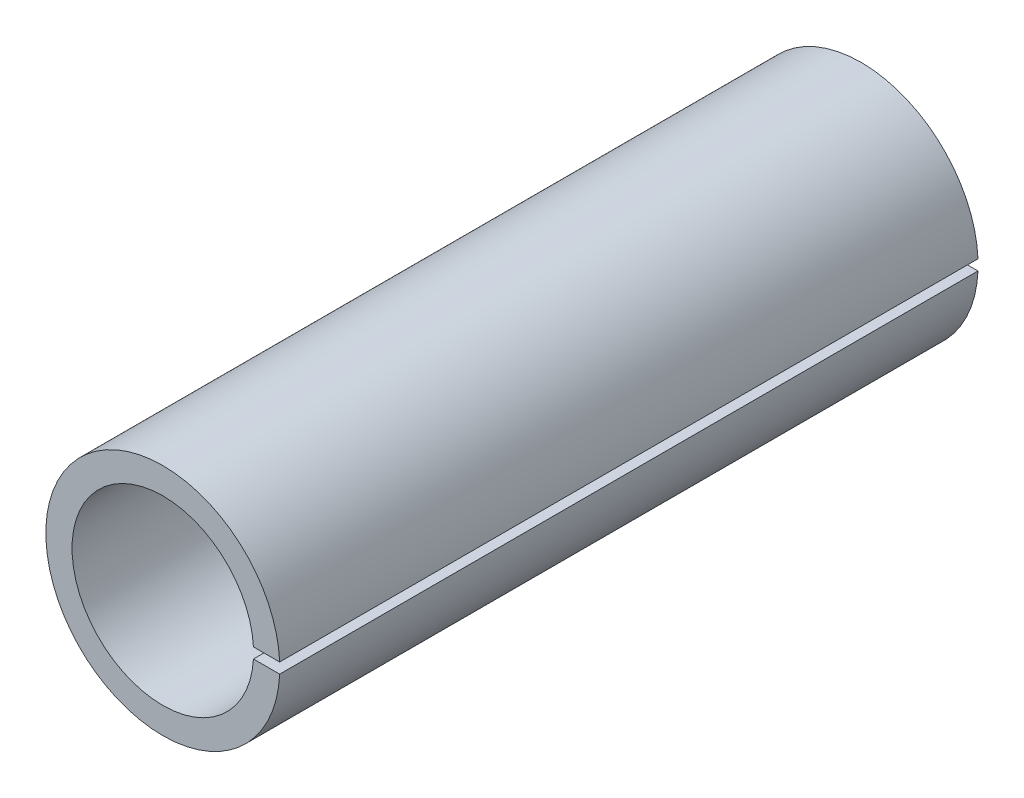
from build123d import *

# Parameters (mm, degrees)
EXTRUDE1_DEPTH      = 12.7
EXTRUDE1_DEPTH_BACK = 12.7


with BuildPart() as part:
    # Sketch1 → Extrude1 (new body, two sides)
    with BuildSketch(Plane.XY) as extrude1_sk:
        with BuildLine():
            Line((3.296500228, 0.1905), (4.250232935, 0.1905))
            ThreePointArc((4.250232935, 0.1905), (-4.2545, 0), (4.250232935, -0.1905))
            Line((4.250232935, -0.1905), (3.296500228, -0.1905))
            ThreePointArc((3.296500228, -0.1905), (-3.302, 0), (3.296500228, 0.1905))
        make_face()
    extrude(amount=EXTRUDE1_DEPTH)
    extrude(extrude1_sk.sketch, amount=-EXTRUDE1_DEPTH_BACK)


solid = part.part
